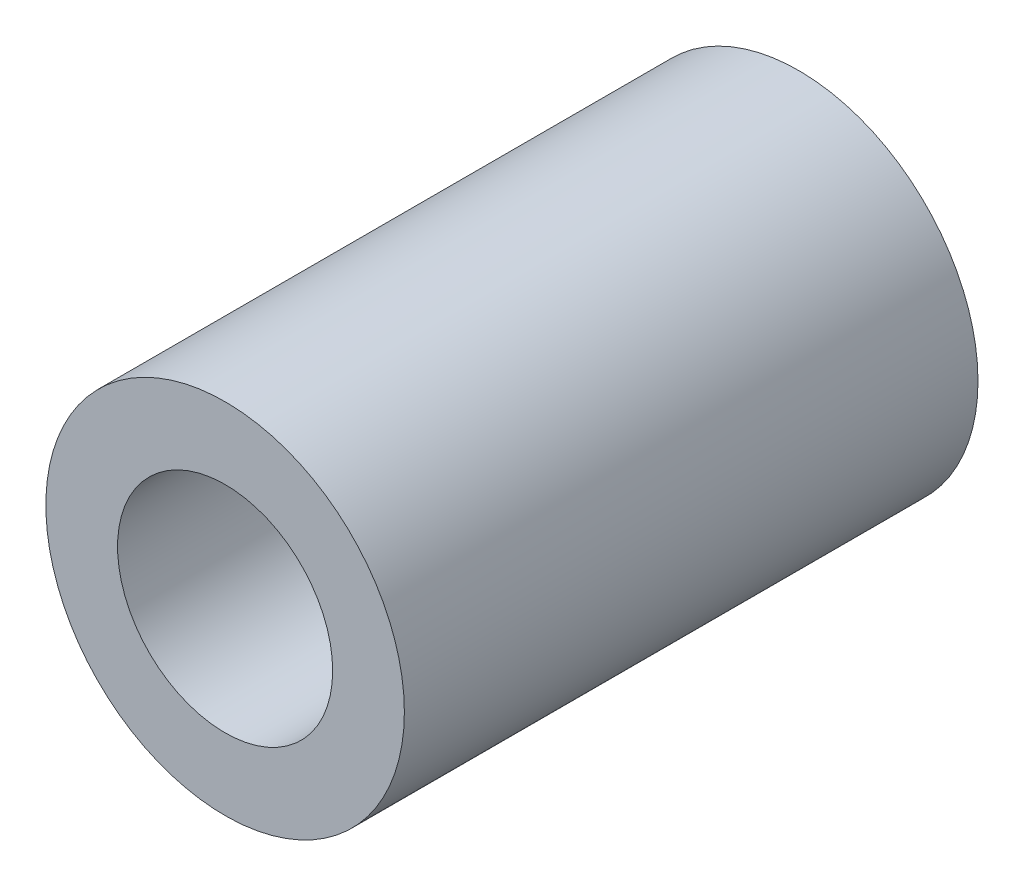
from build123d import *

# Parameters (mm, degrees)
SKETCH2_R           = 2.5
SKETCH2_R_2         = 1.5
BOSS_EXTRUDE1_DEPTH = 8


with BuildPart() as part:
    # Sketch2 → Boss-Extrude1 (new body)
    with BuildSketch(Plane.XY):
        Circle(SKETCH2_R)
        Circle(SKETCH2_R_2, mode=Mode.SUBTRACT)
    extrude(amount=BOSS_EXTRUDE1_DEPTH)


solid = part.part
